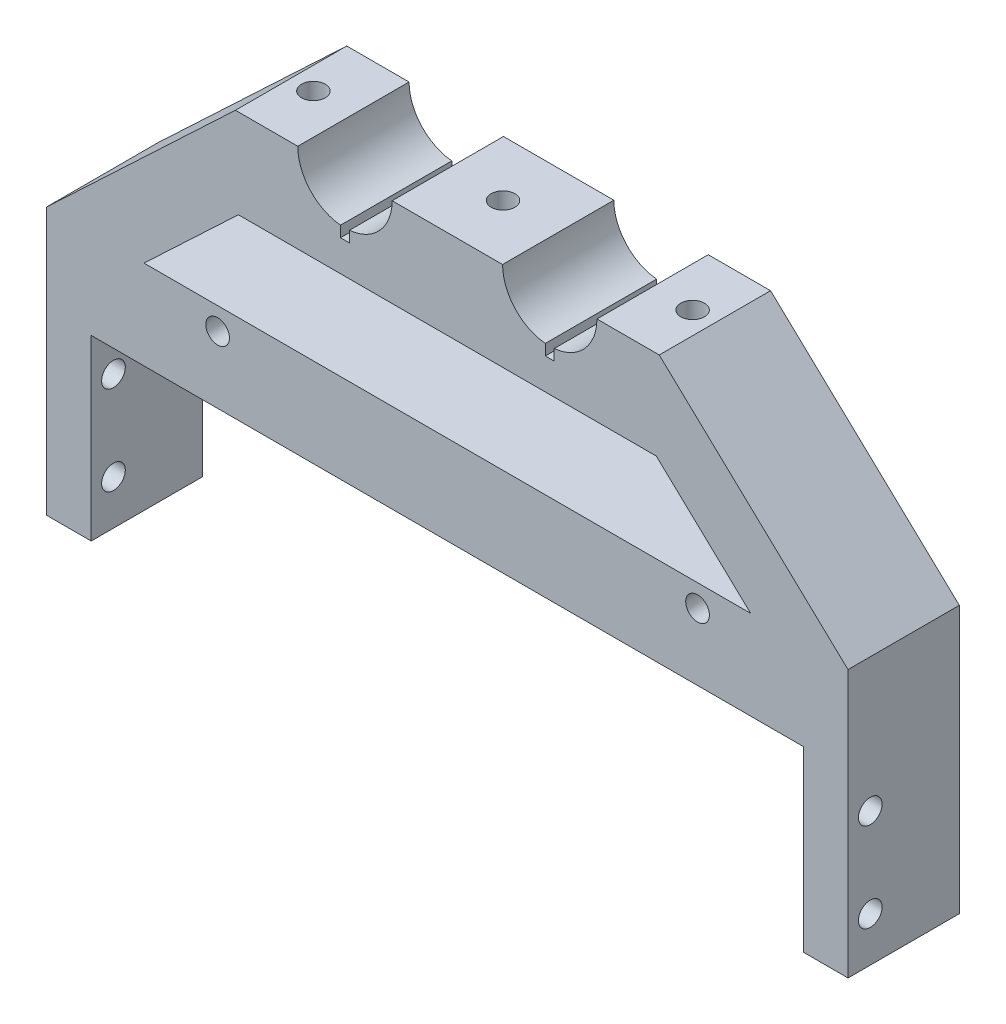
from build123d import *

# Parameters (mm, degrees)
BOSS_EXTRUDE1_DEPTH = 50.8
SKETCH3_R           = 3.3782
CUT_EXTRUDE1_DEPTH  = 25.4
SKETCH4_R           = 3.3782
CUT_EXTRUDE2_DEPTH  = 25.4
SKETCH7_W           = 228.6
SKETCH7_H           = 152.4
CUT_EXTRUDE5_DEPTH  = 19.05
SKETCH8_W           = 228.6
SKETCH8_H           = 25.4
CUT_EXTRUDE6_DEPTH  = 39.37
SKETCH9_R           = 3.3782
CUT_EXTRUDE7_DEPTH  = 27.94
CUT_EXTRUDE8_DEPTH  = 40.64
SKETCH12_W          = 1.27
SKETCH12_H          = 31.75
CUT_EXTRUDE9_DEPTH  = 16.51
CUT_EXTRUDE10_REACH = 33.75
SKETCH13_R          = 3.3782


with BuildPart() as part:
    # Sketch2 → Boss-Extrude1 (new body)
    with BuildSketch(Plane.XY):
        with BuildLine():
            Line((215.9, 0), (228.6, 0))
            Line((228.6, 0), (228.6, 101.6))
            Line((228.6, 101.6), (174.752, 152.4))
            Line((174.752, 152.4), (156.972, 152.4))
            ThreePointArc((156.972, 152.4), (143.51, 138.938), (130.048, 152.4))
            Line((130.048, 152.4), (98.552, 152.4))
            ThreePointArc((98.552, 152.4), (85.09, 138.938), (71.628, 152.4))
            Line((71.628, 152.4), (53.848, 152.4))
            Line((53.848, 152.4), (0, 101.6))
            Line((0, 101.6), (0, 0))
            Line((0, 0), (12.7, 0))
            Line((12.7, 0), (12.7, 76.2))
            Line((12.7, 76.2), (215.9, 76.2))
            Line((215.9, 76.2), (215.9, 0))
        make_face()
    extrude(amount=BOSS_EXTRUDE1_DEPTH)

    # Sketch3 → Cut-Extrude1 (cut)
    with BuildSketch(Plane.ZY):
        with Locations((25.4, 63.5)):
            Circle(SKETCH3_R)
        with Locations((25.4, 38.1)):
            Circle(SKETCH3_R)
    extrude(amount=-CUT_EXTRUDE1_DEPTH, mode=Mode.SUBTRACT)

    # Sketch4 → Cut-Extrude2 (cut)
    with BuildSketch(Plane(origin=(228.6, 0, 0), x_dir=(0, 0, -1), z_dir=(1, 0, 0))):
        with Locations((-25.4, 63.5)):
            Circle(SKETCH4_R)
        with Locations((-25.4, 38.1)):
            Circle(SKETCH4_R)
    extrude(amount=-CUT_EXTRUDE2_DEPTH, mode=Mode.SUBTRACT)

    # Sketch7 → Cut-Extrude5 (cut)
    with BuildSketch(Plane.XY.offset(50.8)):
        with Locations((114.3, 76.2)):
            Rectangle(SKETCH7_W, SKETCH7_H)
    extrude(amount=-CUT_EXTRUDE5_DEPTH, mode=Mode.SUBTRACT)

    # Sketch8 → Cut-Extrude6 (cut)
    with BuildSketch(Plane.XY.offset(31.75)):
        with Locations((114.3, 12.7)):
            Rectangle(SKETCH8_W, SKETCH8_H)
    extrude(amount=-CUT_EXTRUDE6_DEPTH, mode=Mode.SUBTRACT)

    # Sketch9 → Cut-Extrude7 (cut)
    with BuildSketch(Plane(origin=(0, 152.4, 0), x_dir=(1, 0, 0), z_dir=(0, 1, 0))):
        with Locations((60.198, -15.875)):
            Circle(SKETCH9_R)
        with Locations((114.3, -15.875)):
            Circle(SKETCH9_R)
        with Locations((168.402, -15.875)):
            Circle(SKETCH9_R)
    extrude(amount=-CUT_EXTRUDE7_DEPTH, mode=Mode.SUBTRACT)

    # Sketch10 → Cut-Extrude8 (cut)
    with BuildSketch(Plane.XY.offset(31.75)):
        Polygon((27.760759157, 101.6), (54.684759157, 127), (173.915240843, 127), (200.839240843, 101.6), align=None)
    extrude(amount=-CUT_EXTRUDE8_DEPTH, mode=Mode.SUBTRACT)

    # Sketch12 → Cut-Extrude9 (cut)
    with BuildSketch(Plane(origin=(0, 152.4, 0), x_dir=(1, 0, 0), z_dir=(0, 1, 0))):
        with Locations((85.725, -15.875)):
            Rectangle(SKETCH12_W, SKETCH12_H)
        with Locations((84.455, -15.875)):
            Rectangle(SKETCH12_W, SKETCH12_H)
        Polygon((143.51, 0), (142.24, 0), (142.24, -31.75), (144.78, -31.75), (144.78, 0), align=None)
    extrude(amount=-CUT_EXTRUDE9_DEPTH, mode=Mode.SUBTRACT)

    # Sketch13 → Cut-Extrude10 (cut, up to next)
    with BuildSketch(Plane.XY.offset(31.75), mode=Mode.PRIVATE) as cut_extrude10_sk1:
        with Locations((48.768, 95.25)):
            Circle(SKETCH13_R)
    cut_extrude10_tool1 = extrude(cut_extrude10_sk1.sketch, amount=-CUT_EXTRUDE10_REACH, mode=Mode.PRIVATE) & part.part
    add(cut_extrude10_tool1.solids().sort_by_distance((48.768, 95.25, 31.75))[0], mode=Mode.SUBTRACT)
    # Sketch13 → Cut-Extrude10 (cut, up to next)
    with BuildSketch(Plane.XY.offset(31.75), mode=Mode.PRIVATE) as cut_extrude10_sk2:
        with Locations((185.674, 95.25)):
            Circle(SKETCH13_R)
    cut_extrude10_tool2 = extrude(cut_extrude10_sk2.sketch, amount=-CUT_EXTRUDE10_REACH, mode=Mode.PRIVATE) & part.part
    add(cut_extrude10_tool2.solids().sort_by_distance((185.674, 95.25, 31.75))[0], mode=Mode.SUBTRACT)


solid = part.part
